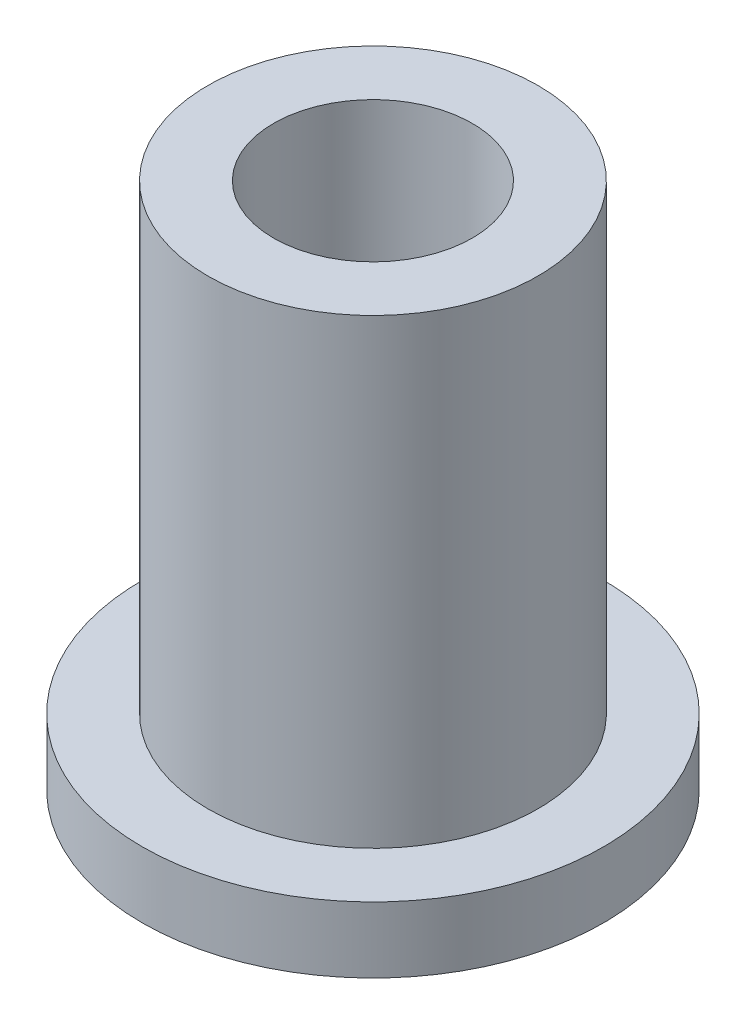
from build123d import *

# Parameters (mm, degrees)
SKETCH2_R           = 3.9751
SKETCH2_R_2         = 2.39395
BOSS_EXTRUDE1_DEPTH = 12.7
SKETCH3_R           = 5.55625
SKETCH3_R_2         = 3.9751
BOSS_EXTRUDE2_DEPTH = 1.5875


with BuildPart() as part:
    # Sketch2 → Boss-Extrude1 (new body)
    with BuildSketch(Plane(origin=(0, 0, 0), x_dir=(1, 0, 0), z_dir=(0, 1, 0))):
        Circle(SKETCH2_R)
        Circle(SKETCH2_R_2, mode=Mode.SUBTRACT)
    extrude(amount=BOSS_EXTRUDE1_DEPTH)

    # Sketch3 → Boss-Extrude2 (add)
    with BuildSketch(Plane(origin=(0, 0, 0), x_dir=(1, 0, 0), z_dir=(0, 1, 0))):
        Circle(SKETCH3_R)
        Circle(SKETCH3_R_2, mode=Mode.SUBTRACT)
    extrude(amount=BOSS_EXTRUDE2_DEPTH)


solid = part.part
